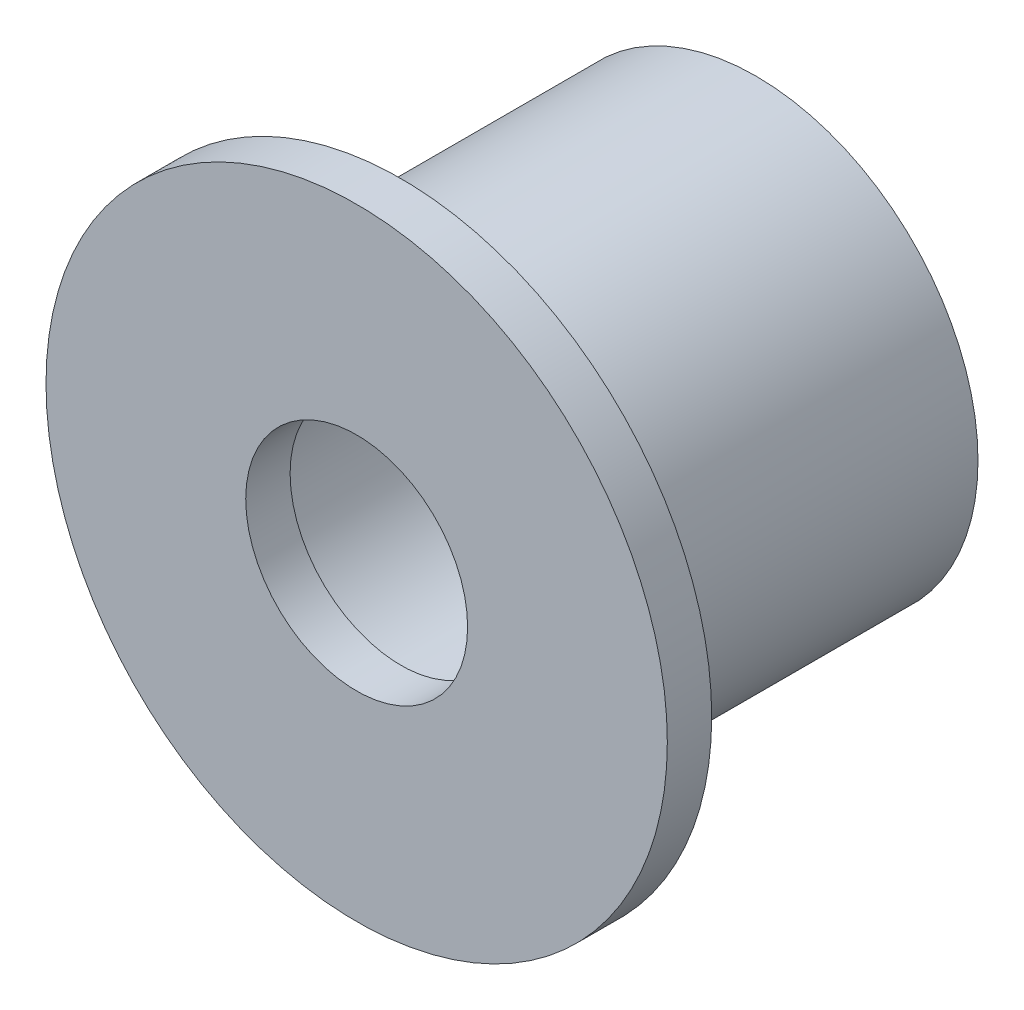
from build123d import *

# Parameters (mm, degrees)
SKETCH_1_R      = 7
SKETCH_1_R_2    = 2.5
EXTRUDE_1_DEPTH = 1
SKETCH_2_R      = 5
SKETCH_2_R_2    = 3
EXTRUDE_2_DEPTH = 8


with BuildPart() as part:
    # 草图1 → 凸台-拉伸1 (new body)
    with BuildSketch(Plane.XY):
        Circle(SKETCH_1_R)
        Circle(SKETCH_1_R_2, mode=Mode.SUBTRACT)
    extrude(amount=EXTRUDE_1_DEPTH)

    # 草图2 → 凸台-拉伸2 (add)
    with BuildSketch(Plane(origin=(0, 0, 0), x_dir=(-1, 0, 0), z_dir=(0, 0, -1))):
        Circle(SKETCH_2_R)
        Circle(SKETCH_2_R_2, mode=Mode.SUBTRACT)
    extrude(amount=EXTRUDE_2_DEPTH)


solid = part.part
